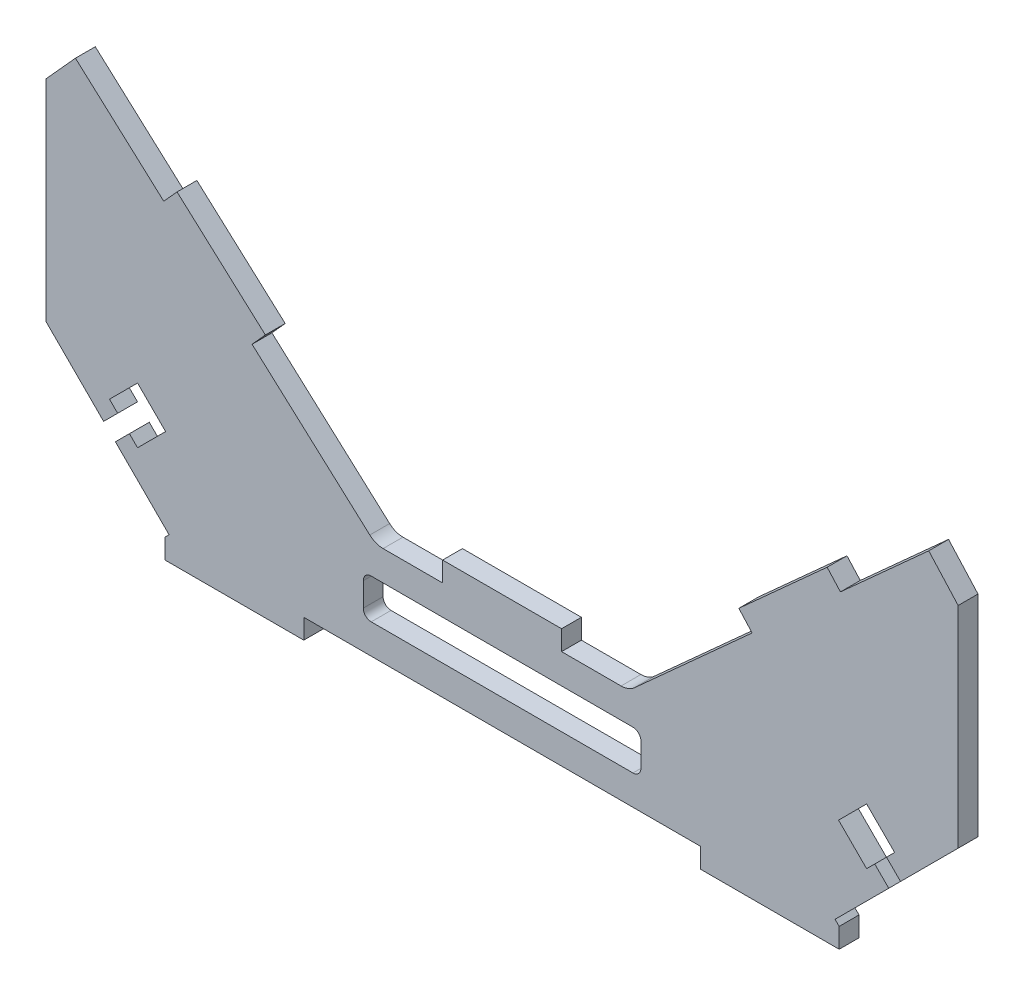
from build123d import *

# Parameters (mm, degrees)
BOSS_EXTRUDE1_DEPTH = 5
CUT_EXTRUDE1_DEPTH  = 10
CUT_EXTRUDE2_DEPTH  = 10
SKETCH5_W           = 5
SKETCH5_H           = 43.988909765
CUT_EXTRUDE4_DEPTH  = 5
CUT_EXTRUDE6_DEPTH  = 10
SKETCH8_W           = 43
SKETCH8_H           = 10
CUT_EXTRUDE7_DEPTH  = 10


with BuildPart() as part:
    # Sketch1 → Boss-Extrude1 (new body)
    with BuildSketch(Plane.XY):
        with BuildLine():
            Line((100, 25), (85, 25))
            ThreePointArc((85, 25), (83.205104603, 25.333271969), (81.649484536, 26.288659794))
            Line((81.649484536, 26.288659794), (51.958762887, 53.092783505))
            Line((51.958762887, 53.092783505), (55.309278351, 56.804123711))
            Line((55.309278351, 56.804123711), (33.041237113, 76.907216495))
            Line((33.041237113, 76.907216495), (29.690721649, 73.195876289))
            Line((29.690721649, 73.195876289), (7.422680412, 93.298969072))
            Line((7.422680412, 93.298969072), (0, 85.076923077))
            Line((0, 85.076923077), (0, 0))
            Line((0, 0), (30, 0))
            Line((30, 0), (30, -5))
            Line((30, -5), (65, -5))
            Line((65, -5), (65, 0))
            Line((65, 0), (165, 0))
            Line((165, 0), (165, -5))
            Line((165, -5), (200, -5))
            Line((200, -5), (200, 0))
            Line((200, 0), (230, 0))
            Line((230, 0), (230, 85.076923077))
            Line((230, 85.076923077), (222.577319588, 93.298969072))
            Line((222.577319588, 93.298969072), (200.309278351, 73.195876289))
            Line((200.309278351, 73.195876289), (196.958762887, 76.907216495))
            Line((196.958762887, 76.907216495), (174.690721649, 56.804123711))
            Line((174.690721649, 56.804123711), (178.041237113, 53.092783505))
            Line((178.041237113, 53.092783505), (148.350515464, 26.288659794))
            ThreePointArc((148.350515464, 26.288659794), (146.794895397, 25.333271969), (145, 25))
            Line((145, 25), (130, 25))
            Line((130, 25), (130, 30))
            Line((130, 30), (100, 30))
            Line((100, 30), (100, 25))
        make_face()
    extrude(amount=BOSS_EXTRUDE1_DEPTH)

    # Sketch2 → Cut-Extrude1 (cut)
    with BuildSketch(Plane(origin=(0, 0, 0), x_dir=(-1, 0, 0), z_dir=(0, 0, -1))):
        Polygon((0, 25), (0, 0), (-25, 0), align=None)
        Polygon((-230, 0), (-205, 0), (-230, 25), align=None)
    extrude(amount=-CUT_EXTRUDE1_DEPTH, mode=Mode.SUBTRACT)

    # Sketch3 → Cut-Extrude2 (cut)
    with BuildSketch(Plane(origin=(0, 0, 0), x_dir=(-1, 0, 0), z_dir=(0, 0, -1))):
        with BuildLine():
            Line((-82, 7.5), (-93.5, 7.5))
            ThreePointArc((-93.5, 7.5), (-94.914213562, 8.085786438), (-95.5, 9.5))
            Line((-95.5, 9.5), (-95.5, 15.5))
            ThreePointArc((-95.5, 15.5), (-94.914213562, 16.914213562), (-93.5, 17.5))
            Line((-93.5, 17.5), (-82, 17.5))
            ThreePointArc((-82, 17.5), (-80.585786438, 16.914213562), (-80, 15.5))
            Line((-80, 15.5), (-80, 9.5))
            ThreePointArc((-80, 9.5), (-80.585786438, 8.085786438), (-82, 7.5))
        make_face()
        with BuildLine():
            Line((-134.5, 9.5), (-134.5, 15.5))
            ThreePointArc((-134.5, 15.5), (-135.085786438, 16.914213562), (-136.5, 17.5))
            Line((-136.5, 17.5), (-148, 17.5))
            ThreePointArc((-148, 17.5), (-149.414213562, 16.914213562), (-150, 15.5))
            Line((-150, 15.5), (-150, 9.5))
            ThreePointArc((-150, 9.5), (-149.414213562, 8.085786438), (-148, 7.5))
            Line((-148, 7.5), (-136.5, 7.5))
            ThreePointArc((-136.5, 7.5), (-135.085786438, 8.085786438), (-134.5, 9.5))
        make_face()
    extrude(amount=-CUT_EXTRUDE2_DEPTH, mode=Mode.SUBTRACT)

    # Sketch5 → Cut-Extrude4 (cut)
    with BuildSketch(Plane(origin=(12.5, 12.5, 0), x_dir=(0, 0, 1), z_dir=(-0.707106781, -0.707106781, 0))):
        with Locations((2.5, 0.781251447)):
            Rectangle(SKETCH5_W, SKETCH5_H)
    cut_extrude4 = extrude(amount=-CUT_EXTRUDE4_DEPTH, mode=Mode.SUBTRACT)

    # Mirror1: Cut-Extrude4 across plane
    add(cut_extrude4.mirror(Plane(origin=(115, 0, 0), x_dir=(0, 0, 1), z_dir=(1, 0, 0))), mode=Mode.SUBTRACT)

    # Sketch7 → Cut-Extrude6 (cut)
    with BuildSketch(Plane(origin=(0, 0, 0), x_dir=(-1, 0, 0), z_dir=(0, 0, -1))):
        Polygon((-23.086143571, 16.055992052), (-21.035533906, 18.106601718), (-18.065685425, 21.076450199), (-16.01507576, 23.127059864), (-23.086143571, 30.198127676), (-30.157211383, 23.127059864), align=None)
        Polygon((-21.035533906, 18.106601718), (-17.5, 14.571067812), (-14.530151519, 17.540916293), (-18.065685425, 21.076450199), align=None)
        Polygon((-213.98492424, 23.127059864), (-206.913856429, 30.198127676), (-199.842788617, 23.127059864), (-206.913856429, 16.055992052), align=None)
        Polygon((-208.964466094, 18.106601718), (-211.934314575, 21.076450199), (-215.469848481, 17.540916293), (-212.5, 14.571067812), align=None)
    extrude(amount=-CUT_EXTRUDE6_DEPTH, mode=Mode.SUBTRACT)

    # Sketch8 → Cut-Extrude7 (cut)
    with BuildSketch(Plane(origin=(0, 0, 0), x_dir=(-1, 0, 0), z_dir=(0, 0, -1))):
        with Locations((-115, 12.5)):
            Rectangle(SKETCH8_W, SKETCH8_H)
    extrude(amount=-CUT_EXTRUDE7_DEPTH, mode=Mode.SUBTRACT)


solid = part.part
